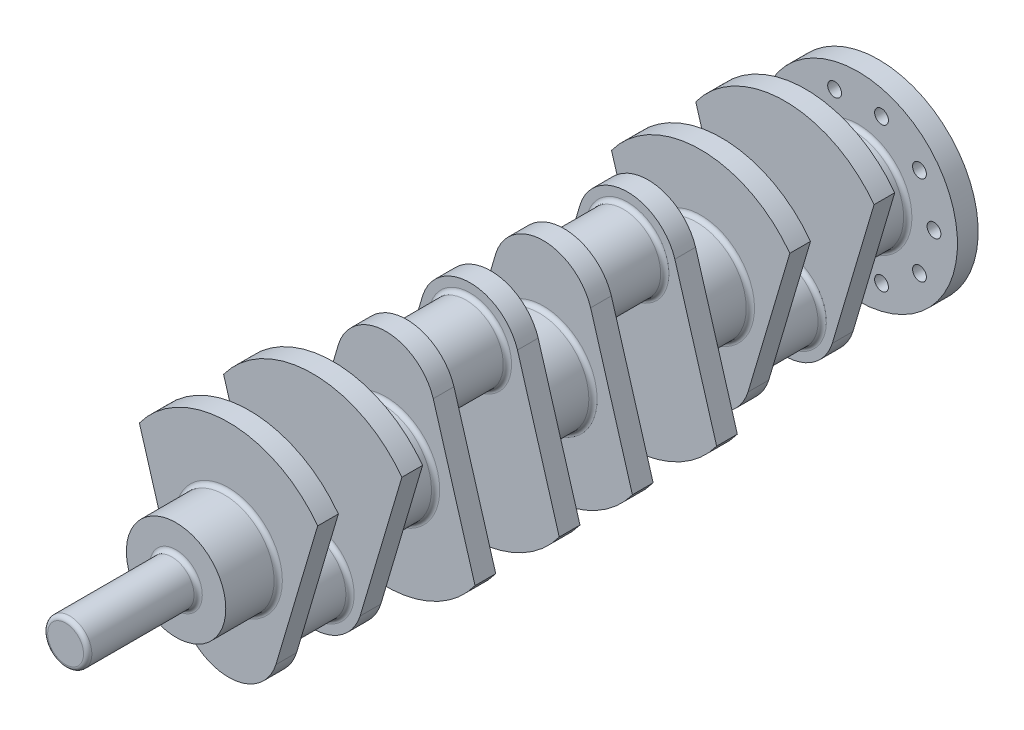
from build123d import *

# Parameters (mm, degrees)
BOSS_EXTRUDE2_DEPTH   = 15
SKETCH3_R             = 27
BOSS_EXTRUDE3_DEPTH   = 46
SKETCH4_R             = 36
BOSS_EXTRUDE4_DEPTH   = 38
BODY_MOVE_COPY1_ANGLE = 180
SKETCH5_R             = 16
BOSS_EXTRUDE5_DEPTH   = 80
SKETCH6_R             = 72
SKETCH6_R_2           = 5
BOSS_EXTRUDE6_DEPTH   = 15
FILLET1_R             = 3
FILLET2_R             = 3


with BuildPart() as part:
    # Sketch2 → Boss-Extrude2 (new body)
    with BuildSketch(Plane.XY):
        with BuildLine():
            ThreePointArc((64.564361287, 47.238154617), (0, 80), (-64.564361287, 47.238154617))
            Line((-64.564361287, 47.238154617), (-34.718395544, -53.520137124))
            ThreePointArc((-34.718395544, -53.520137124), (-4.803007413, -8.321839736), (36, -44))
            ThreePointArc((36, -44), (35.678160264, -48.803007413), (34.718395544, -53.520137124))
            Line((34.718395544, -53.520137124), (64.564361287, 47.238154617))
        make_face()
        with BuildLine():
            ThreePointArc((36, -44), (-4.803007413, -8.321839736), (-34.718395544, -53.520137124))
            Line((-34.718395544, -53.520137124), (-34.302334805, -54.924734637))
            ThreePointArc((-34.302334805, -54.924734637), (0, -80), (34.302334805, -54.924734637))
            Line((34.302334805, -54.924734637), (34.718395544, -53.520137124))
            ThreePointArc((34.718395544, -53.520137124), (35.678160264, -48.803007413), (36, -44))
        make_face()
    boss_extrude2 = extrude(amount=BOSS_EXTRUDE2_DEPTH)

    # Sketch3 → Boss-Extrude3 (add)
    with BuildSketch(Plane(origin=(0, 0, 0), x_dir=(-1, 0, 0), z_dir=(0, 0, -1))):
        with Locations((0, -43.638066069)):
            Circle(SKETCH3_R)
    boss_extrude3 = extrude(amount=BOSS_EXTRUDE3_DEPTH)

    # Sketch4 → Boss-Extrude4 (add)
    with BuildSketch(Plane.XY.offset(15)):
        Circle(SKETCH4_R)
    boss_extrude4 = extrude(amount=BOSS_EXTRUDE4_DEPTH)

    # Mirror1: Boss-Extrude2, Boss-Extrude3, Boss-Extrude4 across plane
    add(boss_extrude2.mirror(Plane(origin=(0, 0, -23), x_dir=(1, 0, 0), z_dir=(0, 0, -1))))
    add(boss_extrude3.mirror(Plane(origin=(0, 0, -23), x_dir=(1, 0, 0), z_dir=(0, 0, -1))))
    add(boss_extrude4.mirror(Plane(origin=(0, 0, -23), x_dir=(1, 0, 0), z_dir=(0, 0, -1))))


with BuildPart() as body_2:
    # Mirror6: mirrored copy
    add(part.part.mirror(Plane(origin=(0, 0, -80), x_dir=(1, 0, 0), z_dir=(0, 0, -1))))


with BuildPart() as body_2_1:
    # Body-Move_Copy1: moved
    add(body_2.part.rotate(Axis((0, 0, -137), (1, 0, 0)), BODY_MOVE_COPY1_ANGLE))


with BuildPart() as body_3:
    # Mirror9: mirrored copy
    add(part.part.mirror(Plane(origin=(0, 0, -194), x_dir=(1, 0, 0), z_dir=(0, 0, -1))))

    # Sketch6 → Boss-Extrude6 (add)
    with BuildSketch(Plane(origin=(0, 0, -441), x_dir=(-1, 0, 0), z_dir=(0, 0, -1))):
        Circle(SKETCH6_R)
        with Locations((55, 0)):
            Circle(SKETCH6_R_2, mode=Mode.SUBTRACT)
        with Locations((44.495934691, -32.328188876)):
            Circle(SKETCH6_R_2, mode=Mode.SUBTRACT)
        with Locations((16.995934691, -52.308108396)):
            Circle(SKETCH6_R_2, mode=Mode.SUBTRACT)
        with Locations((-16.995934691, -52.308108396)):
            Circle(SKETCH6_R_2, mode=Mode.SUBTRACT)
        with Locations((-44.495934691, -32.328188876)):
            Circle(SKETCH6_R_2, mode=Mode.SUBTRACT)
        with Locations((-55, 0)):
            Circle(SKETCH6_R_2, mode=Mode.SUBTRACT)
        with Locations((-44.495934691, 32.328188876)):
            Circle(SKETCH6_R_2, mode=Mode.SUBTRACT)
        with Locations((-16.995934691, 52.308108396)):
            Circle(SKETCH6_R_2, mode=Mode.SUBTRACT)
        with Locations((16.995934691, 52.308108396)):
            Circle(SKETCH6_R_2, mode=Mode.SUBTRACT)
        with Locations((44.495934691, 32.328188876)):
            Circle(SKETCH6_R_2, mode=Mode.SUBTRACT)
    extrude(amount=BOSS_EXTRUDE6_DEPTH)


with BuildPart() as body_4:
    # Mirror9 2: mirrored copy
    add(body_2_1.part.mirror(Plane(origin=(0, 0, -194), x_dir=(1, 0, 0), z_dir=(0, 0, -1))))


with BuildPart() as part_1:
    add(part.part)

    # Sketch5 → Boss-Extrude5 (add)
    with BuildSketch(Plane.XY.offset(53)):
        Circle(SKETCH5_R)
    extrude(amount=BOSS_EXTRUDE5_DEPTH)

    # Combine1: union body 2, body 4, body 3
    add(body_2_1.part)
    add(body_4.part)
    add(body_3.part)

    # Fillet1
    fillet1_edges = [part_1.edges().sort_by_distance(p)[0] for p in [
        (27, -43.638066069, 0),
        (27, -43.638066069, -46),
        (-36, 0, 15),
        (-36, 0, -61),
        (-16, 0, 53),
        (-36, 0, -99),
        (27, 43.638066069, -114),
        (27, 43.638066069, -160),
        (-36, 0, -175),
        (27, 43.638066069, -274),
        (-36, 0, -289),
        (-36, 0, -213),
        (27, 43.638066069, -228),
        (-36, 0, -403),
        (27, -43.638066069, -388),
        (27, -43.638066069, -342),
        (-36, 0, -441),
        (-36, 0, -327),
    ]]
    fillet(fillet1_edges, radius=FILLET1_R)

    # Fillet2
    fillet2_edges = [part_1.edges().sort_by_distance(p)[0] for p in [
        (-16, 0, 133),
    ]]
    fillet(fillet2_edges, radius=FILLET2_R)


solid = part_1.part
